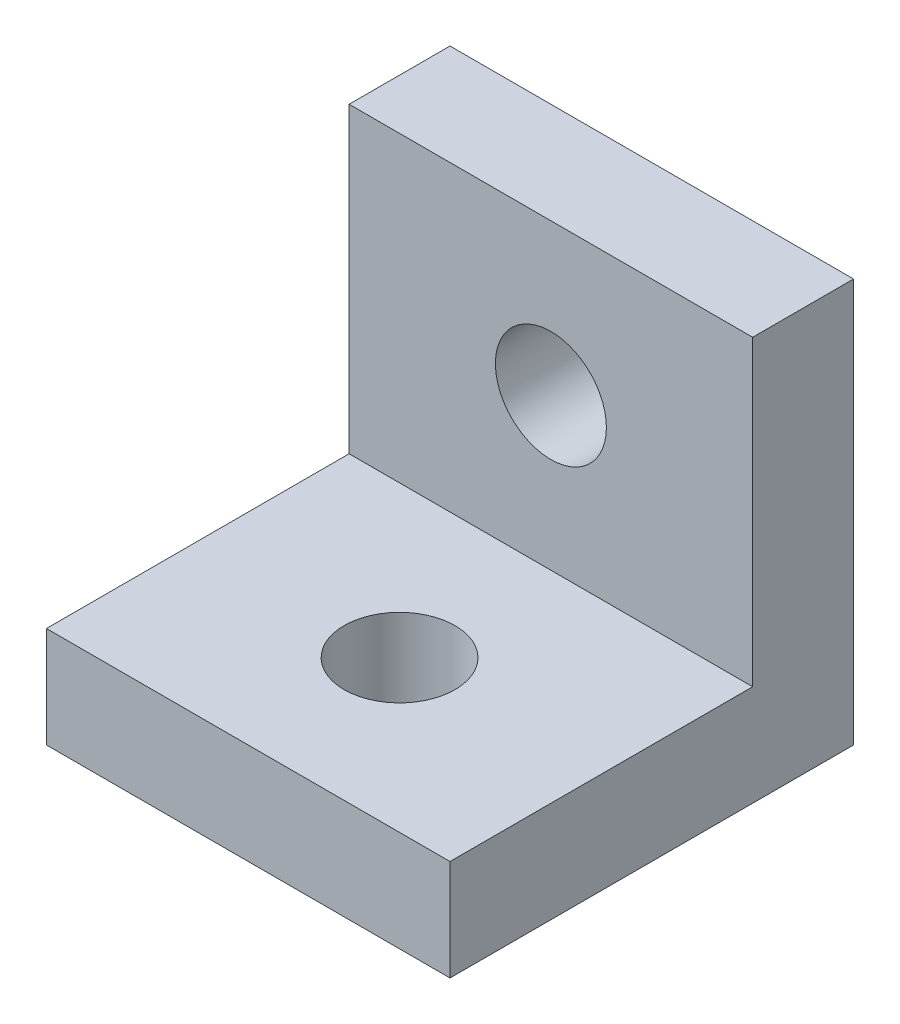
from build123d import *

# Parameters (mm, degrees)
SKETCH1_W           = 10.16
SKETCH1_H           = 10.16
BOSS_EXTRUDE1_DEPTH = 2.54
SKETCH2_W           = 10.16
SKETCH2_H           = 2.54
BOSS_EXTRUDE2_DEPTH = 7.62
SKETCH3_R           = 1.397
CUT_EXTRUDE1_DEPTH  = 10.16
SKETCH4_R           = 1.397
CUT_EXTRUDE2_DEPTH  = 10.16


with BuildPart() as part:
    # Sketch1 → Boss-Extrude1 (new body)
    with BuildSketch(Plane.XY):
        with Locations((5.08, 5.08)):
            Rectangle(SKETCH1_W, SKETCH1_H)
    extrude(amount=BOSS_EXTRUDE1_DEPTH)

    # Sketch2 → Boss-Extrude2 (add)
    with BuildSketch(Plane.XY.offset(2.54)):
        with Locations((5.08, 1.27)):
            Rectangle(SKETCH2_W, SKETCH2_H)
    extrude(amount=BOSS_EXTRUDE2_DEPTH)

    # Sketch3 → Cut-Extrude1 (cut)
    with BuildSketch(Plane.XY.offset(2.54)):
        with Locations((5.08, 6.35)):
            Circle(SKETCH3_R)
    extrude(amount=-CUT_EXTRUDE1_DEPTH, mode=Mode.SUBTRACT)

    # Sketch4 → Cut-Extrude2 (cut)
    with BuildSketch(Plane(origin=(0, 2.54, 0), x_dir=(1, 0, 0), z_dir=(0, 1, 0))):
        with Locations((5.08, -6.35)):
            Circle(SKETCH4_R)
    extrude(amount=-CUT_EXTRUDE2_DEPTH, mode=Mode.SUBTRACT)


solid = part.part
